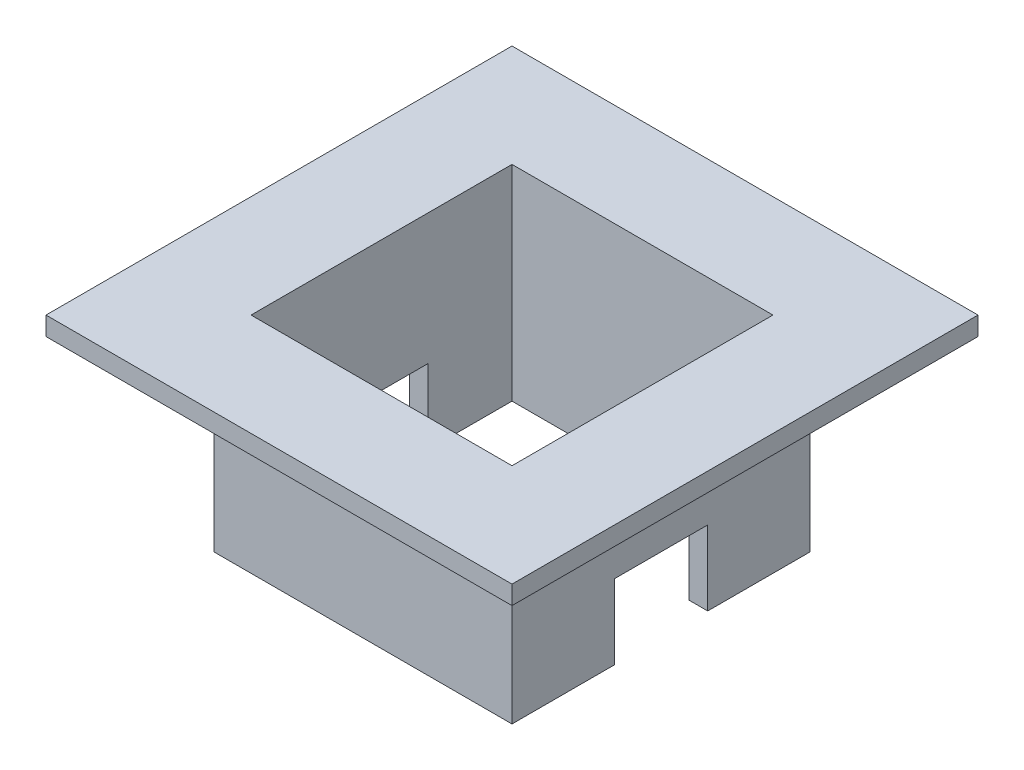
from build123d import *

# Parameters (mm, degrees)
SKETCH1_W           = 32
SKETCH1_H           = 32
SKETCH1_W_2         = 28
SKETCH1_H_2         = 28
BOSS_EXTRUDE1_DEPTH = 20
SKETCH2_W           = 10
SKETCH2_H           = 8
CUT_EXTRUDE1_DEPTH  = 33
SKETCH3_W           = 50
SKETCH3_H           = 50
SKETCH3_W_2         = 28
SKETCH3_H_2         = 28
BOSS_EXTRUDE2_DEPTH = 2


with BuildPart() as part:
    # Sketch1 → Boss-Extrude1 (new body)
    with BuildSketch(Plane(origin=(0, 0, 0), x_dir=(1, 0, 0), z_dir=(0, 1, 0))):
        Rectangle(SKETCH1_W, SKETCH1_H)
        Rectangle(SKETCH1_W_2, SKETCH1_H_2, mode=Mode.SUBTRACT)
    extrude(amount=BOSS_EXTRUDE1_DEPTH)

    # Sketch2 → Cut-Extrude1 (cut, through all)
    with BuildSketch(Plane(origin=(16, 0, 0), x_dir=(0, 0, -1), z_dir=(1, 0, 0))):
        with Locations((0, 4)):
            Rectangle(SKETCH2_W, SKETCH2_H)
    extrude(amount=-CUT_EXTRUDE1_DEPTH, mode=Mode.SUBTRACT)

    # Sketch3 → Boss-Extrude2 (add)
    with BuildSketch(Plane(origin=(0, 20, 0), x_dir=(1, 0, 0), z_dir=(0, 1, 0))):
        Rectangle(SKETCH3_W, SKETCH3_H)
        Rectangle(SKETCH3_W_2, SKETCH3_H_2, mode=Mode.SUBTRACT)
    extrude(amount=BOSS_EXTRUDE2_DEPTH)


solid = part.part
